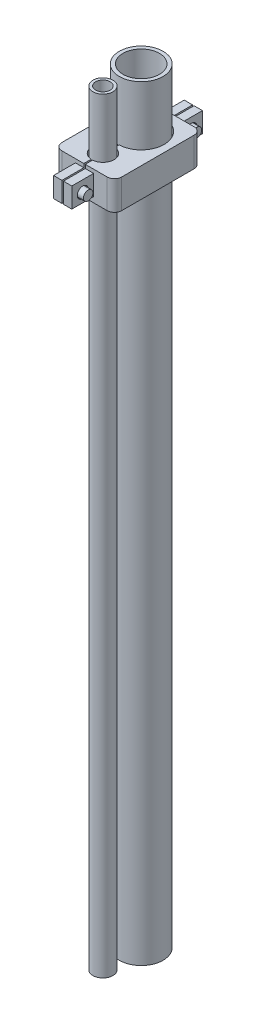
from build123d import *

# Parameters (mm, degrees)
CROQUIS1_R                = 30
CROQUIS1_R_2              = 25
SALIENTE_EXTRUIR1_DEPTH   = 1050
CROQUIS1_R_3              = 13.75
CROQUIS1_R_4              = 10
SALIENTE_EXTRUIR1_2_DEPTH = 1050
SALIENTE_EXTRUIR2_DEPTH   = 20
SALIENTE_EXTRUIR2_2_DEPTH = 20
CROQUIS4_R                = 7.5
CROQUIS4_W                = 30
CROQUIS4_H                = 5
CROQUIS4_H_2              = 7.5
CORTAR_EXTRUIR1_DEPTH     = 20
CROQUIS4_4_R              = 6.5
SALIENTE_EXTRUIR3_DEPTH   = 20
SALIENTE_EXTRUIR3_2_DEPTH = 20


with BuildPart() as part:
    # Croquis1 → Saliente-Extruir1 (new body)
    with BuildSketch(Plane(origin=(0, 0, 0), x_dir=(1, 0, 0), z_dir=(0, 1, 0))):
        Circle(CROQUIS1_R)
        Circle(CROQUIS1_R_2, mode=Mode.SUBTRACT)
    extrude(amount=SALIENTE_EXTRUIR1_DEPTH)


with BuildPart() as body_2:
    # Croquis1 → Saliente-Extruir1 2 (new body)
    with BuildSketch(Plane(origin=(0, 0, 0), x_dir=(1, 0, 0), z_dir=(0, 1, 0))):
        with Locations((0, -52.5)):
            Circle(CROQUIS1_R_3)
        with Locations((0, -52.5)):
            Circle(CROQUIS1_R_4, mode=Mode.SUBTRACT)
    extrude(amount=SALIENTE_EXTRUIR1_2_DEPTH)


with BuildPart() as body_3:
    # Croquis2 → Saliente-Extruir2 (new, symmetric)
    with BuildSketch(Plane(origin=(0, 950, 0), x_dir=(1, 0, 0), z_dir=(0, 1, 0))):
        with BuildLine():
            Line((-12.5, 71.484122983), (-1, 71.484122983))
            Line((-1, 71.484122983), (-1, 31.484122983))
            ThreePointArc((-1, 31.484122983), (-31.5, 0), (-1, -31.484122983))
            Line((-1, -31.484122983), (-1, -37.282822206))
            ThreePointArc((-1, -37.282822206), (-15.25, -52.5), (-1, -67.717177794))
            Line((-1, -67.717177794), (-1, -107.717177794))
            Line((-1, -107.717177794), (-12.5, -107.717177794))
            Line((-12.5, -107.717177794), (-12.5, -77.717177794))
            Line((-12.5, -77.717177794), (-31, -77.717177794))
            ThreePointArc((-31, -77.717177794), (-38.071067812, -74.788245605), (-41, -67.717177794))
            Line((-41, -67.717177794), (-41, 31.484122983))
            ThreePointArc((-41, 31.484122983), (-38.071067812, 38.555190795), (-31, 41.484122983))
            Line((-31, 41.484122983), (-12.5, 41.484122983))
            Line((-12.5, 41.484122983), (-12.5, 71.484122983))
        make_face()
    extrude(amount=SALIENTE_EXTRUIR2_DEPTH, both=True)


with BuildPart() as body_4:
    # Croquis2 → Saliente-Extruir2 2 (new, symmetric)
    with BuildSketch(Plane(origin=(0, 950, 0), x_dir=(1, 0, 0), z_dir=(0, 1, 0))):
        with BuildLine():
            Line((41, 31.484122983), (41, -67.717177794))
            ThreePointArc((41, -67.717177794), (38.071067812, -74.788245605), (31, -77.717177794))
            Line((31, -77.717177794), (12.5, -77.717177794))
            Line((12.5, -77.717177794), (12.5, -107.717177794))
            Line((12.5, -107.717177794), (1, -107.717177794))
            Line((1, -107.717177794), (1, -67.717177794))
            ThreePointArc((1, -67.717177794), (15.25, -52.5), (1, -37.282822206))
            Line((1, -37.282822206), (1, -31.484122983))
            ThreePointArc((1, -31.484122983), (31.5, 0), (1, 31.484122983))
            Line((1, 31.484122983), (1, 71.484122983))
            Line((1, 71.484122983), (12.5, 71.484122983))
            Line((12.5, 71.484122983), (12.5, 41.484122983))
            Line((12.5, 41.484122983), (31, 41.484122983))
            ThreePointArc((31, 41.484122983), (38.071067812, 38.555190795), (41, 31.484122983))
        make_face()
    extrude(amount=SALIENTE_EXTRUIR2_2_DEPTH, both=True)


with BuildPart() as cortar_extruir1_tool:
    # Croquis4 → Cortar-Extruir1 (new, symmetric)
    with BuildSketch(Plane(origin=(0, 0, 0), x_dir=(0, 0, -1), z_dir=(1, 0, 0))):
        with Locations((56.484122983, 950)):
            Circle(CROQUIS4_R)
        with Locations((-92.717177794, 950)):
            Circle(CROQUIS4_R)
        with Locations((-92.717177794, 967.5)):
            Rectangle(CROQUIS4_W, CROQUIS4_H)
        with Locations((-92.717177794, 933.75)):
            Rectangle(CROQUIS4_W, CROQUIS4_H_2)
        with Locations((56.484122983, 933.75)):
            Rectangle(CROQUIS4_W, CROQUIS4_H_2)
        with Locations((56.484122983, 967.5)):
            Rectangle(CROQUIS4_W, CROQUIS4_H)
    extrude(amount=CORTAR_EXTRUIR1_DEPTH, both=True)


with BuildPart() as body_3_1:
    add(body_3.part)

    # Cortar-Extruir1: cut by cortar_extruir1_tool
    add(cortar_extruir1_tool.part, mode=Mode.SUBTRACT)


with BuildPart() as body_4_1:
    add(body_4.part)

    # Cortar-Extruir1: cut by cortar_extruir1_tool
    add(cortar_extruir1_tool.part, mode=Mode.SUBTRACT)


with BuildPart() as body_5:
    # Croquis4_4 → Saliente-Extruir3 (new, symmetric)
    with BuildSketch(Plane(origin=(0, 0, 0), x_dir=(0, 0, -1), z_dir=(1, 0, 0))):
        with Locations((-92.717177794, 950)):
            Circle(CROQUIS4_4_R)
    extrude(amount=SALIENTE_EXTRUIR3_DEPTH, both=True)


with BuildPart() as body_6:
    # Croquis4_4 → Saliente-Extruir3 2 (new, symmetric)
    with BuildSketch(Plane(origin=(0, 0, 0), x_dir=(0, 0, -1), z_dir=(1, 0, 0))):
        with Locations((56.484122983, 950)):
            Circle(CROQUIS4_4_R)
    extrude(amount=SALIENTE_EXTRUIR3_2_DEPTH, both=True)


solid = Compound([part.part, body_2.part, body_3_1.part, body_4_1.part, body_5.part, body_6.part])
